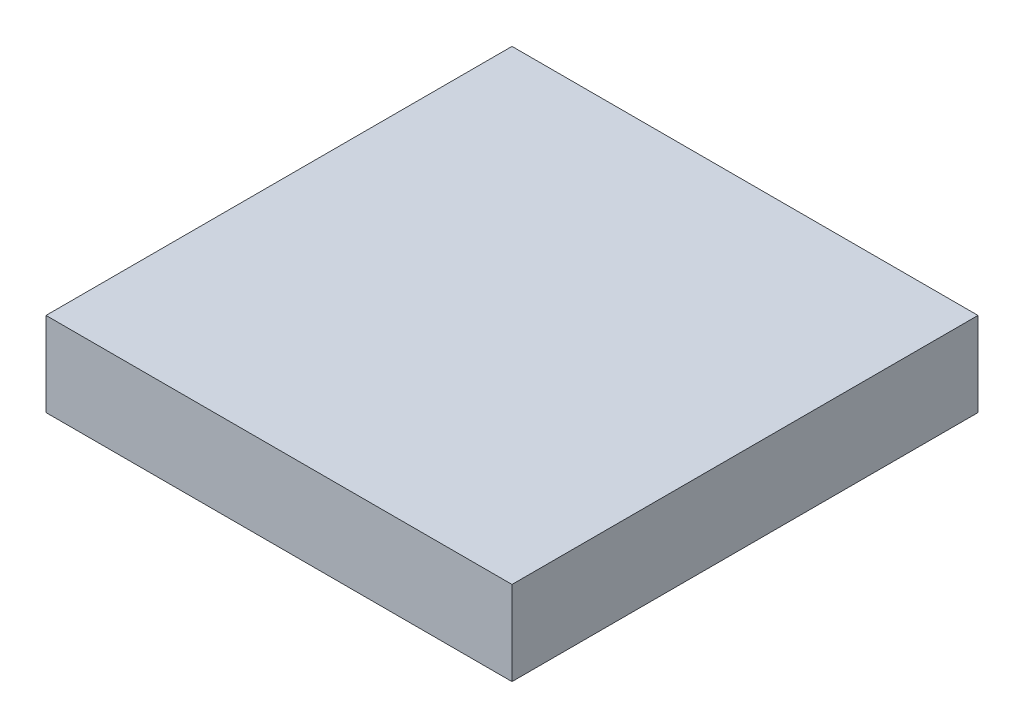
from build123d import *

# Parameters (mm, degrees)
SALIENTE_EXTRUIR1_DEPTH  = 32
CORTAR_EXTRUIR1_DEPTH    = 33
SALIENTE_EXTRUIR12_DEPTH = 0.01
SALIENTE_EXTRUIR13_DEPTH = 0.01
SALIENTE_EXTRUIR14_DEPTH = 0.01
SALIENTE_EXTRUIR15_DEPTH = 0.01


with BuildPart() as part:
    # Croquis1 → Saliente-Extruir1 (new body)
    with BuildSketch(Plane.XY):
        Polygon((-51.959662641, 8.927829358), (-51.959662641, 3.148169014), (-35.959662641, -4.290206314), (-19.959662641, 3.148169014), (-19.959662641, 8.927829358), align=None)
    extrude(amount=SALIENTE_EXTRUIR1_DEPTH)

    # Croquis2 → Cortar-Extruir1 (cut)
    with BuildSketch(Plane(origin=(-19.959662641, 0, 0), x_dir=(0, 0, -1), z_dir=(1, 0, 0))):
        Polygon((0, -4.290206314), (-16, -4.290206314), (0, 3.148169014), align=None)
        Polygon((-32, -4.290206314), (-32, 3.148169014), (-16, -4.290206314), align=None)
    extrude(amount=-CORTAR_EXTRUIR1_DEPTH, mode=Mode.SUBTRACT)

    # Croquis16 → Saliente-Extruir12 (add)
    with BuildSketch(Plane(origin=(0, -9.644179557, 4.483564205), x_dir=(-1, 0, 0), z_dir=(0, -0.906796627, 0.421568354))):
        with BuildLine():
            Line((47.568325111, -29.981567998), (36.071815605, -29.981567998))
            Line((36.071815605, -29.981567998), (24.351000171, -29.981567998))
            ThreePointArc((24.351000171, -29.981567998), (35.959662641, -18.372905528), (47.568325111, -29.981567998))
        make_face()
    extrude(amount=SALIENTE_EXTRUIR12_DEPTH)

    # Croquis17 → Saliente-Extruir13 (add)
    with BuildSketch(Plane(origin=(-8.030792992, -17.274294748, 0), x_dir=(-0.906796627, 0.421568354, 0), z_dir=(-0.421568354, -0.906796627, 0))):
        with BuildLine():
            Line((48.080668577, -16), (48.080668577, -27.608491723))
            ThreePointArc((48.080668577, -27.608491723), (36.472176853, -16), (48.080668577, -4.391508277))
            Line((48.080668577, -4.391508277), (48.080668577, -16))
        make_face()
    extrude(amount=SALIENTE_EXTRUIR13_DEPTH)

    # Croquis18 → Saliente-Extruir14 (add)
    with BuildSketch(Plane(origin=(0, 2.588676805, 1.203471855), x_dir=(-1, 0, 0), z_dir=(0, -0.906796627, -0.421568354))):
        with BuildLine():
            Line((47.567066817, 0.962202745), (35.959662641, 0.962202745))
            Line((35.959662641, 0.962202745), (24.352258465, 0.962202745))
            ThreePointArc((24.352258465, 0.962202745), (35.959662641, -10.64520143), (47.567066817, 0.962202745))
        make_face()
    extrude(amount=SALIENTE_EXTRUIR14_DEPTH)

    # Croquis19 → Saliente-Extruir15 (add)
    with BuildSketch(Plane(origin=(-4.750700642, 10.218791996, 0), x_dir=(-0.906796627, -0.421568354, 0), z_dir=(0.421568354, -0.906796627, 0))):
        with BuildLine():
            Line((17.142987404, -4.396515697), (17.142987404, -16))
            Line((17.142987404, -16), (17.142987404, -27.603484303))
            ThreePointArc((17.142987404, -27.603484303), (28.746471707, -16), (17.142987404, -4.396515697))
        make_face()
    extrude(amount=SALIENTE_EXTRUIR15_DEPTH)


solid = part.part
